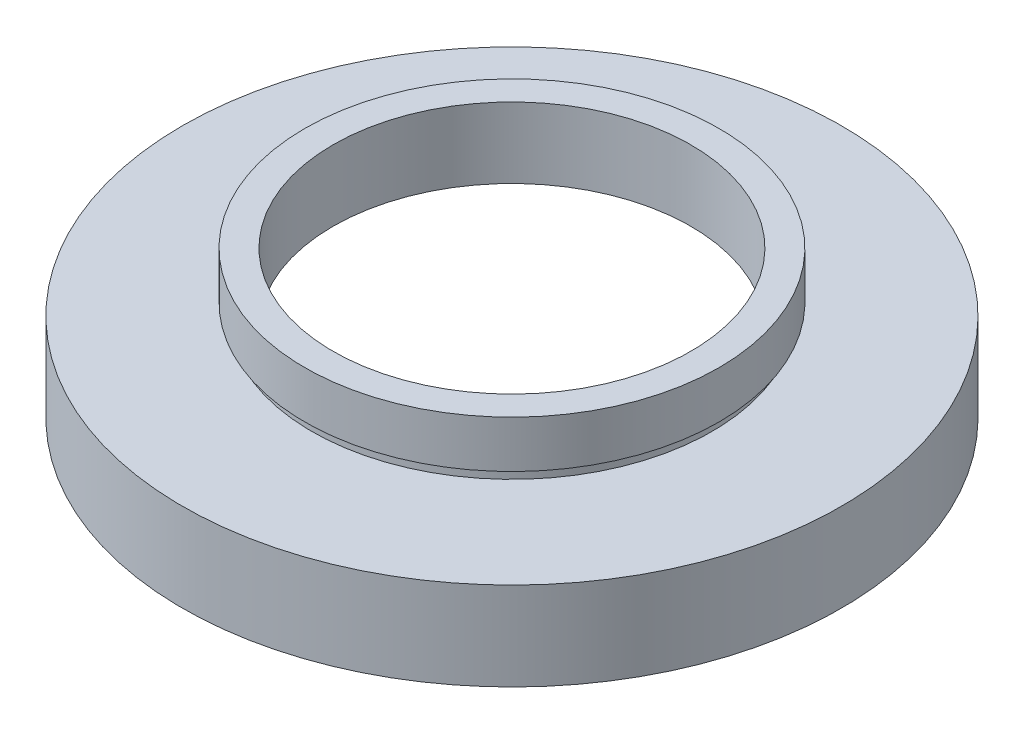
from build123d import *


with BuildPart() as part:
    # 草图1 → 旋转1 (revolve)
    with BuildSketch(Plane.XY, mode=Mode.PRIVATE) as revolve_1_sk:
        Polygon((25.3, 0), (25.3, 5.5), (25.95, 5.5), (25.95, 6.5), (15.2, 6.5), (15.2, 12.5), (17.6, 12.5), (17.6, 8.5), (17, 8.5), (17, 7.5), (28, 7.5), (28, 0), align=None)
    revolve(revolve_1_sk.sketch.rotate(Axis((0, 16.886018237, 0), (0, -1, 0)), 180), axis=Axis((0, 16.886018237, 0), (0, -1, 0)))  # turned: the seam where the file's is


solid = part.part
